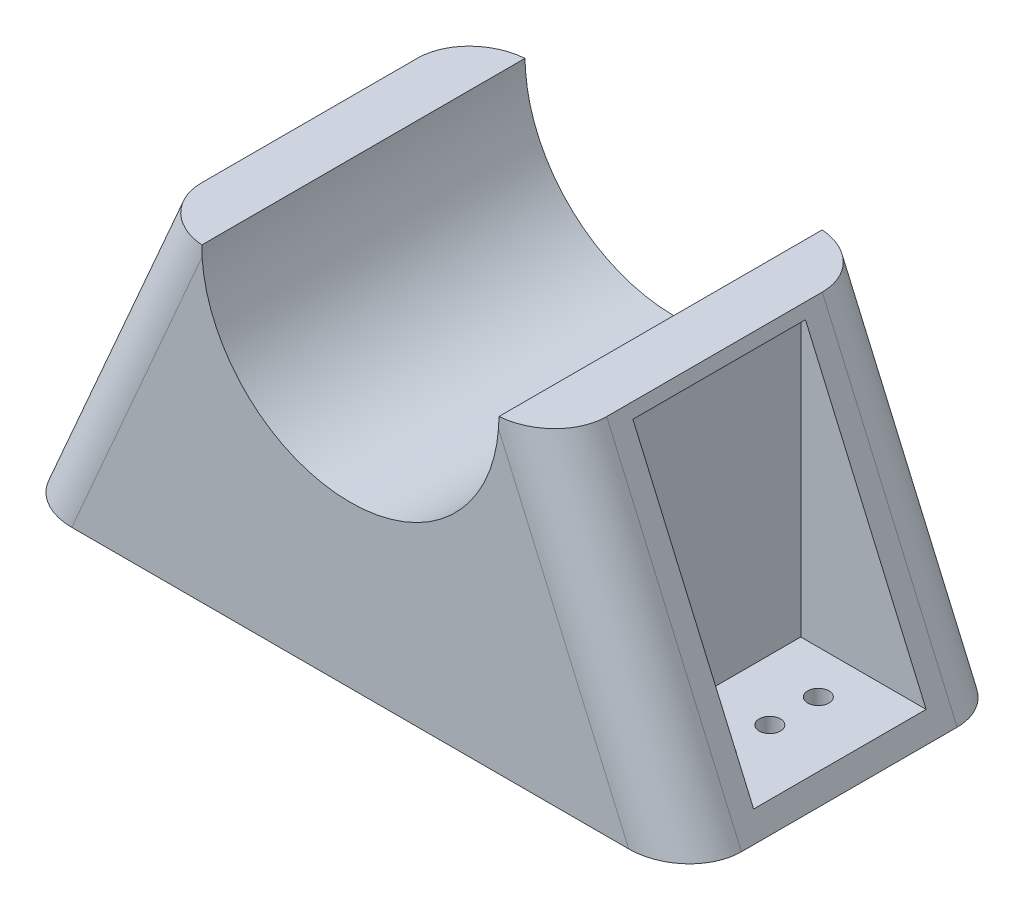
from build123d import *

# Parameters (mm, degrees)
SKETCH1_R               = 47.7
SKETCH1_R_2             = 35
BOSS_EXTRUDE1_DEPTH     = 76.2
CUT_EXTRUDE1_DEPTH      = 1
CUT_EXTRUDE1_DEPTH_BACK = 77.2
BOSS_EXTRUDE2_DEPTH     = 76.2
BOSS_EXTRUDE4_DEPTH     = 76.2
FILLET2_R               = 12.7
SKETCH6_W               = 40.64
SKETCH6_H               = 65.287260423
CUT_EXTRUDE3_DEPTH      = 101.6
CUT_EXTRUDE4_START      = -6.0800001
SKETCH7_R               = 2.5
CUT_EXTRUDE4_DEPTH      = 74.907260623
LPATTERN1_COUNT         = 3
LPATTERN1_PITCH         = 11.43
BOSS_EXTRUDE5_DEPTH     = 76.2
FILLET3_R               = 12.7
SKETCH8_W               = 40.64
SKETCH8_H               = 65.287260423
CUT_EXTRUDE5_DEPTH      = 76.2
CUT_EXTRUDE6_START      = -6.0800001
SKETCH9_R               = 2.5
CUT_EXTRUDE6_DEPTH      = 74.907260623
LPATTERN2_COUNT         = 3
LPATTERN2_PITCH         = 12.62


with BuildPart() as part:
    # Sketch1 → Boss-Extrude1 (new body)
    with BuildSketch(Plane.XY):
        Circle(SKETCH1_R)
        Circle(SKETCH1_R_2, mode=Mode.SUBTRACT)
    extrude(amount=BOSS_EXTRUDE1_DEPTH)

    # Sketch2 → Cut-Extrude1 (cut, two sides)
    with BuildSketch(Plane.XY.offset(76.2)) as cut_extrude1_sk:
        Polygon((-285.983619069, 0), (-50.977699953, 0), (54.190264056, 0), (289.196183172, 0), (289.196183172, 470.011838232), (-285.983619069, 470.011838232), align=None)
    extrude(amount=CUT_EXTRUDE1_DEPTH, mode=Mode.SUBTRACT)
    extrude(cut_extrude1_sk.sketch, amount=-CUT_EXTRUDE1_DEPTH_BACK, mode=Mode.SUBTRACT)

    # Sketch3 → Boss-Extrude2 (add)
    with BuildSketch(Plane(origin=(0, 0, 0), x_dir=(-1, 0, 0), z_dir=(0, 0, -1))):
        with BuildLine():
            ThreePointArc((-4.283714166, -47.507260423), (-35.210958278, -32.178850463), (-47.7, 0))
            Line((-47.7, 0), (-47.7, -47.507260423))
            Line((-47.7, -47.507260423), (-4.283714166, -47.507260423))
        make_face()
        with BuildLine():
            Line((47.7, -47.507260423), (47.7, 0))
            ThreePointArc((47.7, 0), (35.210958278, -32.178850463), (4.283714166, -47.507260423))
            Line((4.283714166, -47.507260423), (47.7, -47.507260423))
        make_face()
        with BuildLine():
            Line((-4.283714166, -47.507260423), (-47.7, -47.507260423))
            Line((-47.7, -47.507260423), (-47.7, -72.907260423))
            Line((-47.7, -72.907260423), (47.7, -72.907260423))
            Line((47.7, -72.907260423), (47.7, -47.507260423))
            Line((47.7, -47.507260423), (4.283714166, -47.507260423))
            ThreePointArc((4.283714166, -47.507260423), (0, -47.7), (-4.283714166, -47.507260423))
        make_face()
    extrude(amount=-BOSS_EXTRUDE2_DEPTH)

    # Sketch5 → Boss-Extrude4 (add)
    with BuildSketch(Plane(origin=(0, 0, 0), x_dir=(-1, 0, 0), z_dir=(0, 0, -1))):
        Polygon((-47.7, 0), (-47.7, -72.907260423), (-79.45, -72.907260423), align=None)
    extrude(amount=-BOSS_EXTRUDE4_DEPTH)

    # Fillet2
    fillet2_edges = [part.edges().sort_by_distance(p)[0] for p in [
        (63.575, -36.453630212, 0),
        (63.575, -36.453630212, 76.2),
    ]]
    fillet(fillet2_edges, radius=FILLET2_R)

    # Sketch6 → Cut-Extrude3 (cut)
    with BuildSketch(Plane(origin=(47.7, 0, 0), x_dir=(0, 0, -1), z_dir=(1, 0, 0))):
        with Locations((-38.1, -35.183630212)):
            Rectangle(SKETCH6_W, SKETCH6_H)
    extrude(amount=CUT_EXTRUDE3_DEPTH, mode=Mode.SUBTRACT)

    # Sketch7 → Cut-Extrude4 (cut)
    with BuildSketch(Plane(origin=(0, -67.827260423, 0), x_dir=(1, 0, 0), z_dir=(0, 1, 0)).offset(CUT_EXTRUDE4_START)):
        with Locations((61.997737475, -50.8)):
            Circle(SKETCH7_R)
    cut_extrude4 = extrude(amount=CUT_EXTRUDE4_DEPTH, mode=Mode.SUBTRACT)

    # LPattern1: Cut-Extrude4 ×3
    with Locations(*[(0, 0, -i * LPATTERN1_PITCH) for i in range(1, LPATTERN1_COUNT)]):
        add(cut_extrude4, mode=Mode.SUBTRACT)

    # Sketch4 → Boss-Extrude5 (add)
    with BuildSketch(Plane(origin=(0, 0, 0), x_dir=(-1, 0, 0), z_dir=(0, 0, -1))):
        Polygon((47.7, 0), (47.7, -72.907260423), (79.45, -72.907260423), align=None)
    extrude(amount=-BOSS_EXTRUDE5_DEPTH)

    # Fillet3
    fillet3_edges = [part.edges().sort_by_distance(p)[0] for p in [
        (-63.575, -36.453630212, 0),
        (-63.575, -36.453630212, 76.2),
    ]]
    fillet(fillet3_edges, radius=FILLET3_R)

    # Sketch8 → Cut-Extrude5 (cut)
    with BuildSketch(Plane.ZY.offset(47.7)):
        with Locations((38.1, -35.183630212)):
            Rectangle(SKETCH8_W, SKETCH8_H)
    extrude(amount=CUT_EXTRUDE5_DEPTH, mode=Mode.SUBTRACT)

    # Sketch9 → Cut-Extrude6 (cut)
    with BuildSketch(Plane(origin=(0, -67.827260423, 0), x_dir=(1, 0, 0), z_dir=(0, 1, 0)).offset(CUT_EXTRUDE6_START)):
        with Locations((-61.997737475, -50.8)):
            Circle(SKETCH9_R)
    cut_extrude6 = extrude(amount=CUT_EXTRUDE6_DEPTH, mode=Mode.SUBTRACT)

    # LPattern2: Cut-Extrude6 ×3
    with Locations(*[(0, 0, -i * LPATTERN2_PITCH) for i in range(1, LPATTERN2_COUNT)]):
        add(cut_extrude6, mode=Mode.SUBTRACT)


solid = part.part
